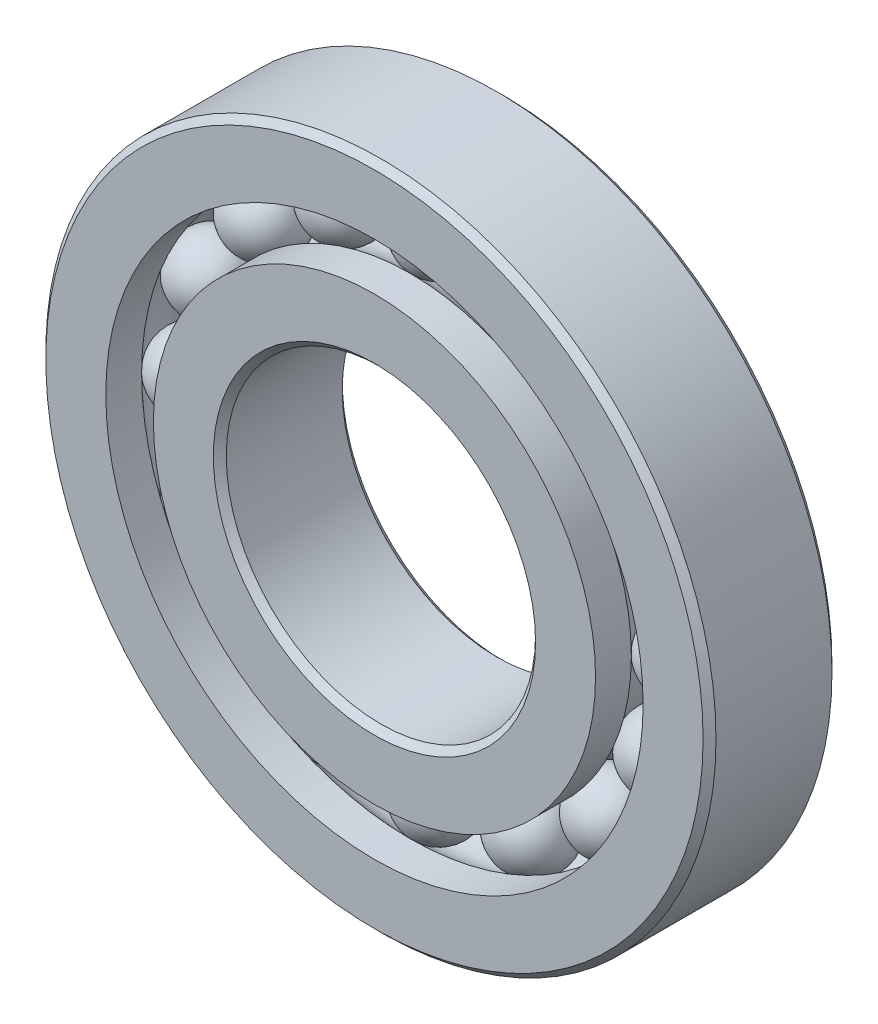
from build123d import *

# Parameters (mm, degrees)
CIRPATTERN1_COUNT = 16


with BuildPart() as part:
    # Sketch1 → Revolve1 (revolve)
    with BuildSketch(Plane(origin=(0, 0, 0), x_dir=(0, 0, -1), z_dir=(1, 0, 0))):
        with BuildLine():
            Line((3.571875, 20.6375), (-3.571875, 20.6375))
            Line((-3.571875, 20.6375), (-3.96875, 20.240625))
            Line((-3.96875, 20.240625), (-3.96875, 16.546634615))
            Line((-3.96875, 16.546634615), (-1.763888889, 16.546634615))
            ThreePointArc((-1.763888889, 16.546634615), (0, 17.374425982), (1.763888889, 16.546634615))
            Line((1.763888889, 16.546634615), (3.96875, 16.546634615))
            Line((3.96875, 16.546634615), (3.96875, 20.240625))
            Line((3.96875, 20.240625), (3.571875, 20.6375))
        make_face()
    revolve(axis=Axis((0, 0, 3.96875), (0, 0, -1)))


with BuildPart() as body_2:
    # Sketch3 → Revolve3 (revolve)
    with BuildSketch(Plane(origin=(0, 0, 0), x_dir=(0, 0, -1), z_dir=(1, 0, 0))):
        with BuildLine():
            Line((-3.96875, 13.615865385), (-1.763888889, 13.615865385))
            ThreePointArc((-1.763888889, 13.615865385), (0, 12.788074018), (1.763888889, 13.615865385))
            Line((1.763888889, 13.615865385), (3.96875, 13.615865385))
            Line((3.96875, 13.615865385), (3.96875, 9.921875))
            Line((3.96875, 9.921875), (3.571875, 9.525))
            Line((3.571875, 9.525), (-3.571875, 9.525))
            Line((-3.571875, 9.525), (-3.96875, 9.921875))
            Line((-3.96875, 9.921875), (-3.96875, 13.615865385))
        make_face()
    revolve(axis=Axis((0, 0, 3.96875), (0, 0, -1)))


with BuildPart() as body_3:
    # Sketch4 → Revolve4 (revolve)
    with BuildSketch(Plane(origin=(0, 0, 0), x_dir=(0, 0, -1), z_dir=(1, 0, 0))):
        with BuildLine():
            Line((-2.293175982, 15.08125), (2.293175982, 15.08125))
            ThreePointArc((2.293175982, 15.08125), (0, 17.374425982), (-2.293175982, 15.08125))
        make_face()
    revolve(axis=Axis((0, 15.08125, 2.293175982), (0, 0, -1)))


with BuildPart() as cirpattern1_1:
    # CirPattern1: pattern copy
    add(body_3.part.rotate(Axis((0, 0, -3.96875), (0, 0, 1)), 1 * 360 / CIRPATTERN1_COUNT))


with BuildPart() as cirpattern1_2:
    # CirPattern1: pattern copy
    add(body_3.part.rotate(Axis((0, 0, -3.96875), (0, 0, 1)), 2 * 360 / CIRPATTERN1_COUNT))


with BuildPart() as cirpattern1_3:
    # CirPattern1: pattern copy
    add(body_3.part.rotate(Axis((0, 0, -3.96875), (0, 0, 1)), 3 * 360 / CIRPATTERN1_COUNT))


with BuildPart() as cirpattern1_4:
    # CirPattern1: pattern copy
    add(body_3.part.rotate(Axis((0, 0, -3.96875), (0, 0, 1)), 4 * 360 / CIRPATTERN1_COUNT))


with BuildPart() as cirpattern1_5:
    # CirPattern1: pattern copy
    add(body_3.part.rotate(Axis((0, 0, -3.96875), (0, 0, 1)), 5 * 360 / CIRPATTERN1_COUNT))


with BuildPart() as cirpattern1_6:
    # CirPattern1: pattern copy
    add(body_3.part.rotate(Axis((0, 0, -3.96875), (0, 0, 1)), 6 * 360 / CIRPATTERN1_COUNT))


with BuildPart() as cirpattern1_7:
    # CirPattern1: pattern copy
    add(body_3.part.rotate(Axis((0, 0, -3.96875), (0, 0, 1)), 7 * 360 / CIRPATTERN1_COUNT))


with BuildPart() as cirpattern1_8:
    # CirPattern1: pattern copy
    add(body_3.part.rotate(Axis((0, 0, -3.96875), (0, 0, 1)), 8 * 360 / CIRPATTERN1_COUNT))


with BuildPart() as cirpattern1_9:
    # CirPattern1: pattern copy
    add(body_3.part.rotate(Axis((0, 0, -3.96875), (0, 0, 1)), 9 * 360 / CIRPATTERN1_COUNT))


with BuildPart() as cirpattern1_10:
    # CirPattern1: pattern copy
    add(body_3.part.rotate(Axis((0, 0, -3.96875), (0, 0, 1)), 10 * 360 / CIRPATTERN1_COUNT))


with BuildPart() as cirpattern1_11:
    # CirPattern1: pattern copy
    add(body_3.part.rotate(Axis((0, 0, -3.96875), (0, 0, 1)), 11 * 360 / CIRPATTERN1_COUNT))


with BuildPart() as cirpattern1_12:
    # CirPattern1: pattern copy
    add(body_3.part.rotate(Axis((0, 0, -3.96875), (0, 0, 1)), 12 * 360 / CIRPATTERN1_COUNT))


with BuildPart() as cirpattern1_13:
    # CirPattern1: pattern copy
    add(body_3.part.rotate(Axis((0, 0, -3.96875), (0, 0, 1)), 13 * 360 / CIRPATTERN1_COUNT))


with BuildPart() as cirpattern1_14:
    # CirPattern1: pattern copy
    add(body_3.part.rotate(Axis((0, 0, -3.96875), (0, 0, 1)), 14 * 360 / CIRPATTERN1_COUNT))


with BuildPart() as cirpattern1_15:
    # CirPattern1: pattern copy
    add(body_3.part.rotate(Axis((0, 0, -3.96875), (0, 0, 1)), 15 * 360 / CIRPATTERN1_COUNT))


solid = Compound([part.part, body_2.part, body_3.part, cirpattern1_1.part, cirpattern1_2.part, cirpattern1_3.part, cirpattern1_4.part, cirpattern1_5.part, cirpattern1_6.part, cirpattern1_7.part, cirpattern1_8.part, cirpattern1_9.part, cirpattern1_10.part, cirpattern1_11.part, cirpattern1_12.part, cirpattern1_13.part, cirpattern1_14.part, cirpattern1_15.part])
